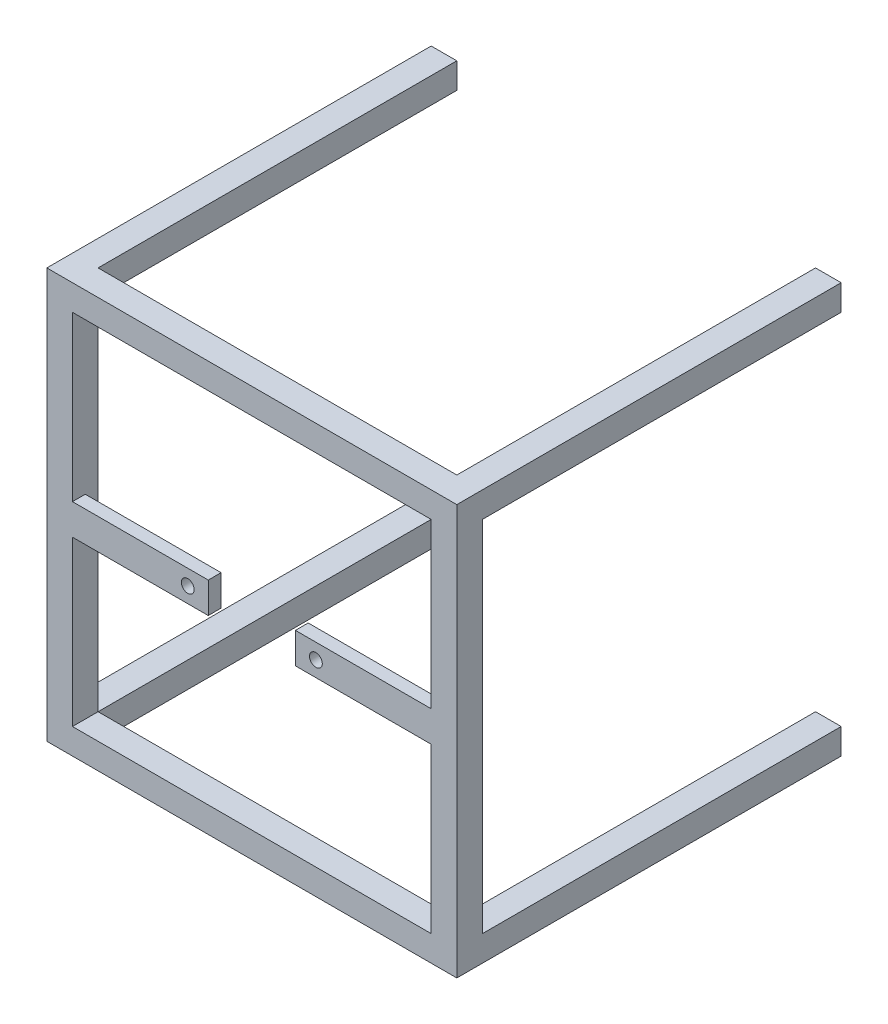
from build123d import *

# Parameters (mm, degrees)
CROQUIS2_W                   = 160
CROQUIS2_H                   = 160
CROQUIS2_W_2                 = 140
CROQUIS2_H_2                 = 140
SALIENTE_EXTRUIR1_DEPTH      = 10
CROQUIS3_W                   = 152
CROQUIS3_H                   = 152
CROQUIS3_W_2                 = 148
CROQUIS3_H_2                 = 148
CORTAR_EXTRUIR1_DEPTH        = 3.5
SALIENTE_EXTRUIR2_DEPTH      = 140
SALIENTE_EXTRUIR2_DEPTH_BACK = 10
CROQUIS4_W                   = 10
CROQUIS4_H                   = 10
CROQUIS7_W                   = 160
CROQUIS7_H                   = 160
CROQUIS7_W_2                 = 140
CROQUIS7_H_2                 = 140
SALIENTE_EXTRUIR3_DEPTH      = 10
CROQUIS8_W                   = 63
CROQUIS8_H                   = 12
CROQUIS8_R                   = 2.5
SALIENTE_EXTRUIR4_DEPTH      = 5
CROQUIS9_W                   = 10
CROQUIS9_H                   = 160
CORTAR_EXTRUIR2_DEPTH        = 278.128129211


with BuildPart() as part:
    # Croquis2 → Saliente-Extruir1 (new body)
    with BuildSketch(Plane.XY):
        with Locations((80, -80)):
            Rectangle(CROQUIS2_W, CROQUIS2_H)
        with Locations((80, -80)):
            Rectangle(CROQUIS2_W_2, CROQUIS2_H_2, mode=Mode.SUBTRACT)
    extrude(amount=SALIENTE_EXTRUIR1_DEPTH)

    # Croquis3 → Cortar-Extruir1 (cut)
    with BuildSketch(Plane.XY.offset(10)):
        with Locations((80, -80)):
            Rectangle(CROQUIS3_W, CROQUIS3_H)
        with Locations((80, -80)):
            Rectangle(CROQUIS3_W_2, CROQUIS3_H_2, mode=Mode.SUBTRACT)
    extrude(amount=-CORTAR_EXTRUIR1_DEPTH, mode=Mode.SUBTRACT)

    # Croquis4 → Saliente-Extruir2 (add, two sides: drawn at the far end of the back side and taken through both)
    with BuildSketch(Plane.XY.offset(10).offset(-SALIENTE_EXTRUIR2_DEPTH_BACK)):
        with Locations((5, -5)):
            Rectangle(CROQUIS4_W, CROQUIS4_H)
        with Locations((155, -5)):
            Rectangle(CROQUIS4_W, CROQUIS4_H)
        with Locations((155, -155)):
            Rectangle(CROQUIS4_W, CROQUIS4_H)
        with Locations((5, -155)):
            Rectangle(CROQUIS4_W, CROQUIS4_H)
    extrude(amount=SALIENTE_EXTRUIR2_DEPTH + SALIENTE_EXTRUIR2_DEPTH_BACK)

    # Croquis7 → Saliente-Extruir3 (add)
    with BuildSketch(Plane.XY.offset(150)):
        with Locations((80, -80)):
            Rectangle(CROQUIS7_W, CROQUIS7_H)
        with Locations((80, -80)):
            Rectangle(CROQUIS7_W_2, CROQUIS7_H_2, mode=Mode.SUBTRACT)
    extrude(amount=SALIENTE_EXTRUIR3_DEPTH)

    # Croquis8 → Saliente-Extruir4 (add)
    # profile 1 of 2: a face of its own
    with BuildSketch(Plane.XY.offset(160)):
        with Locations((31.5, -80)):
            Rectangle(CROQUIS8_W, CROQUIS8_H)
        with Locations((55, -80)):
            Circle(CROQUIS8_R, mode=Mode.SUBTRACT)
    # profile 2 of 2: a face of its own
    with BuildSketch(Plane.XY.offset(160)):
        with Locations((128.5, -80)):
            Rectangle(CROQUIS8_W, CROQUIS8_H)
        with Locations((105, -80)):
            Circle(CROQUIS8_R, mode=Mode.SUBTRACT)
    extrude(amount=-SALIENTE_EXTRUIR4_DEPTH)

    # Croquis9 → Cortar-Extruir2 (cut, through all)
    with BuildSketch(Plane.ZY):
        with Locations((5, -80)):
            Rectangle(CROQUIS9_W, CROQUIS9_H)
    extrude(amount=-CORTAR_EXTRUIR2_DEPTH, mode=Mode.SUBTRACT)


solid = part.part
